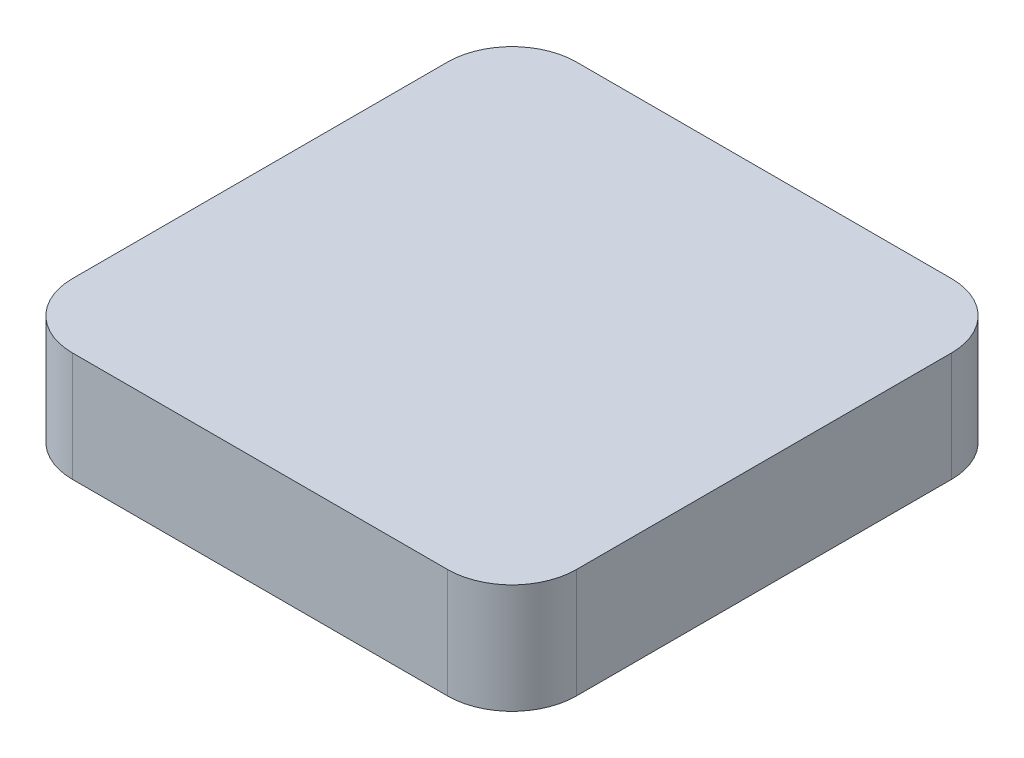
from build123d import *

# Parameters (mm, degrees)
SKETCH_1_W      = 39.1
SKETCH_1_H      = 39.1
EXTRUDE_1_DEPTH = 8.5
FILLET_1_R      = 5


with BuildPart() as part:
    # 草图1 → 凸台-拉伸1 (new body)
    with BuildSketch(Plane(origin=(0, 0, 0), x_dir=(1, 0, 0), z_dir=(0, 1, 0))):
        with Locations((-9.357264957, -1.420299145)):
            Rectangle(SKETCH_1_W, SKETCH_1_H)
    extrude(amount=EXTRUDE_1_DEPTH)

    # 圆角1
    fillet_1_edges = [part.edges().sort_by_distance(p)[0] for p in [
        (10.192735043, 4.25, 20.970299145),
        (-28.907264957, 4.25, 20.970299145),
        (-28.907264957, 4.25, -18.129700855),
        (10.192735043, 4.25, -18.129700855),
    ]]
    fillet(fillet_1_edges, radius=FILLET_1_R)


solid = part.part
